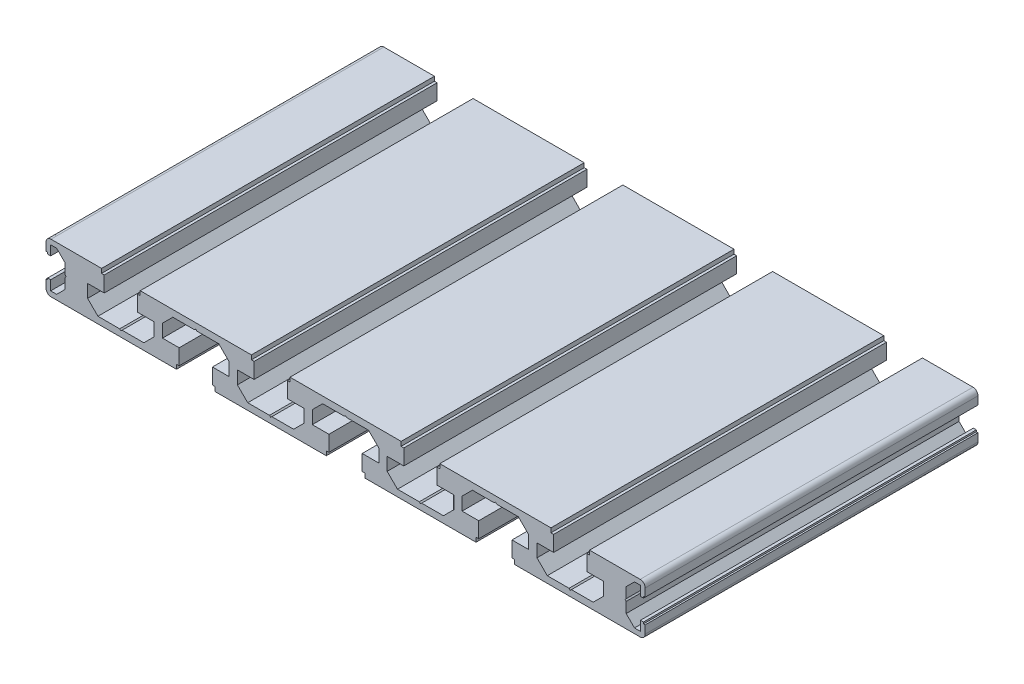
from build123d import *

# Parameters (mm, degrees)
EXTRUDE_1_DEPTH     = 100
CUT_EXTRUDE_1_DEPTH = 100


with BuildPart() as part:
    # Model → Бобышка-Вытянуть1 (new body)
    with BuildSketch(Plane.XY):
        with BuildLine():
            Line((-12.5, 11.1), (-12, 11.1))
            Line((-12, 11.1), (-12, 10.6))
            Line((-12, 10.6), (-11.1, 10.6))
            Line((-11.1, 10.6), (-11.1, 13.5))
            Line((-11.1, 13.5), (-9.3, 13.5))
            Line((-9.3, 13.5), (-6.8, 11))
            Line((-6.8, 11), (-6.8, 4))
            Line((-6.8, 4), (-9.3, 1.5))
            Line((-9.3, 1.5), (-11.1, 1.5))
            Line((-11.1, 1.5), (-11.1, 4.4))
            Line((-11.1, 4.4), (-12, 4.4))
            Line((-12, 4.4), (-12, 3.9))
            Line((-12, 3.9), (-12.5, 3.9))
            Line((-12.5, 3.9), (-12.5, 1.5))
            ThreePointArc((-12.5, 1.5), (-12.060660172, 0.439339828), (-11, 0))
            Line((-11, 0), (26.7, 0))
            Line((26.7, 0), (26.7, 1.3))
            Line((26.7, 1.3), (27.5, 1.3))
            Line((27.5, 1.3), (27.5, 6))
            Line((27.5, 6), (22.5, 6))
            Line((22.5, 6), (22.5, 9.9))
            Line((22.5, 9.9), (25.6, 13))
            Line((25.6, 13), (39.4, 13))
            Line((39.4, 13), (42.5, 9.9))
            Line((42.5, 9.9), (42.5, 6))
            Line((42.5, 6), (37.5, 6))
            Line((37.5, 6), (37.5, 1.3))
            Line((37.5, 1.3), (38.3, 1.3))
            Line((38.3, 1.3), (38.3, 0))
            Line((38.3, 0), (71.7, 0))
            Line((71.7, 0), (71.7, 1.3))
            Line((71.7, 1.3), (72.5, 1.3))
            Line((72.5, 1.3), (72.5, 6))
            Line((72.5, 6), (67.5, 6))
            Line((67.5, 6), (67.5, 9.9))
            Line((67.5, 9.9), (70.6, 13))
            Line((70.6, 13), (84.4, 13))
            Line((84.4, 13), (87.5, 9.9))
            Line((87.5, 9.9), (87.5, 6))
            Line((87.5, 6), (82.5, 6))
            Line((82.5, 6), (82.5, 1.3))
            Line((82.5, 1.3), (83.3, 1.3))
            Line((83.3, 1.3), (83.3, 0))
            Line((83.3, 0), (116.7, 0))
            Line((116.7, 0), (116.7, 1.3))
            Line((116.7, 1.3), (117.5, 1.3))
            Line((117.5, 1.3), (117.5, 6))
            Line((117.5, 6), (112.5, 6))
            Line((112.5, 6), (112.5, 9.9))
            Line((112.5, 9.9), (115.6, 13))
            Line((115.6, 13), (129.4, 13))
            Line((129.4, 13), (132.5, 9.9))
            Line((132.5, 9.9), (132.5, 6))
            Line((132.5, 6), (127.5, 6))
            Line((127.5, 6), (127.5, 1.3))
            Line((127.5, 1.3), (128.3, 1.3))
            Line((128.3, 1.3), (128.3, 0))
            Line((128.3, 0), (166, 0))
            ThreePointArc((166, 0), (167.060660172, 0.439339828), (167.5, 1.5))
            Line((167.5, 1.5), (167.5, 3.9))
            Line((167.5, 3.9), (167, 3.9))
            Line((167, 3.9), (167, 4.4))
            Line((167, 4.4), (166.1, 4.4))
            Line((166.1, 4.4), (166.1, 1.5))
            Line((166.1, 1.5), (164.3, 1.5))
            Line((164.3, 1.5), (161.8, 4))
            Line((161.8, 4), (161.8, 11))
            Line((161.8, 11), (164.3, 13.5))
            Line((164.3, 13.5), (166.1, 13.5))
            Line((166.1, 13.5), (166.1, 10.6))
            Line((166.1, 10.6), (167, 10.6))
            Line((167, 10.6), (167, 11.1))
            Line((167, 11.1), (167.5, 11.1))
            Line((167.5, 11.1), (167.5, 13.5))
            ThreePointArc((167.5, 13.5), (167.060660172, 14.560660172), (166, 15))
            Line((166, 15), (150.8, 15))
            Line((150.8, 15), (150.8, 13.7))
            Line((150.8, 13.7), (150, 13.7))
            Line((150, 13.7), (150, 9))
            Line((150, 9), (155, 9))
            Line((155, 9), (155, 5.1))
            Line((155, 5.1), (151.9, 2))
            Line((151.9, 2), (138.1, 2))
            Line((138.1, 2), (135, 5.1))
            Line((135, 5.1), (135, 9))
            Line((135, 9), (140, 9))
            Line((140, 9), (140, 13.7))
            Line((140, 13.7), (139.2, 13.7))
            Line((139.2, 13.7), (139.2, 15))
            Line((139.2, 15), (105.8, 15))
            Line((105.8, 15), (105.8, 13.7))
            Line((105.8, 13.7), (105, 13.7))
            Line((105, 13.7), (105, 9))
            Line((105, 9), (110, 9))
            Line((110, 9), (110, 5.1))
            Line((110, 5.1), (106.9, 2))
            Line((106.9, 2), (93.1, 2))
            Line((93.1, 2), (90, 5.1))
            Line((90, 5.1), (90, 9))
            Line((90, 9), (95, 9))
            Line((95, 9), (95, 13.7))
            Line((95, 13.7), (94.2, 13.7))
            Line((94.2, 13.7), (94.2, 15))
            Line((94.2, 15), (60.8, 15))
            Line((60.8, 15), (60.8, 13.7))
            Line((60.8, 13.7), (60, 13.7))
            Line((60, 13.7), (60, 9))
            Line((60, 9), (65, 9))
            Line((65, 9), (65, 5.1))
            Line((65, 5.1), (61.9, 2))
            Line((61.9, 2), (48.1, 2))
            Line((48.1, 2), (45, 5.1))
            Line((45, 5.1), (45, 9))
            Line((45, 9), (50, 9))
            Line((50, 9), (50, 13.7))
            Line((50, 13.7), (49.2, 13.7))
            Line((49.2, 13.7), (49.2, 15))
            Line((49.2, 15), (15.8, 15))
            Line((15.8, 15), (15.8, 13.7))
            Line((15.8, 13.7), (15, 13.7))
            Line((15, 13.7), (15, 9))
            Line((15, 9), (20, 9))
            Line((20, 9), (20, 5.1))
            Line((20, 5.1), (16.9, 2))
            Line((16.9, 2), (3.1, 2))
            Line((3.1, 2), (0, 5.1))
            Line((0, 5.1), (0, 9))
            Line((0, 9), (5, 9))
            Line((5, 9), (5, 13.7))
            Line((5, 13.7), (4.2, 13.7))
            Line((4.2, 13.7), (4.2, 15))
            Line((4.2, 15), (-11, 15))
            ThreePointArc((-11, 15), (-12.060660172, 14.560660172), (-12.5, 13.5))
            Line((-12.5, 13.5), (-12.5, 11.1))
        make_face()
    extrude(amount=EXTRUDE_1_DEPTH)

    # Эскиз1 → Вырез-Вытянуть1 (cut)
    with BuildSketch(Plane.XY.offset(100)):
        Polygon((-6.8, 7.853553391), (-6.446446609, 7.5), (-6.8, 7.146446609), align=None)
        Polygon((9.646446609, 2), (10, 1.646446609), (10.353553391, 2), align=None)
        Polygon((32.146446609, 13), (32.5, 13.353553391), (32.853553391, 13), align=None)
        Polygon((54.646446609, 2), (55, 1.646446609), (55.353553391, 2), align=None)
        Polygon((77.146446609, 13), (77.5, 13.353553391), (77.853553391, 13), align=None)
        Polygon((99.646446609, 2), (100, 1.646446609), (100.353553391, 2), align=None)
        Polygon((122.146446609, 13), (122.5, 13.353553391), (122.853553391, 13), align=None)
        Polygon((144.646446609, 2), (145, 1.646446609), (145.353553391, 2), align=None)
        Polygon((161.8, 7.853553391), (161.446446609, 7.5), (161.8, 7.146446609), align=None)
    extrude(amount=-CUT_EXTRUDE_1_DEPTH, mode=Mode.SUBTRACT)


solid = part.part
